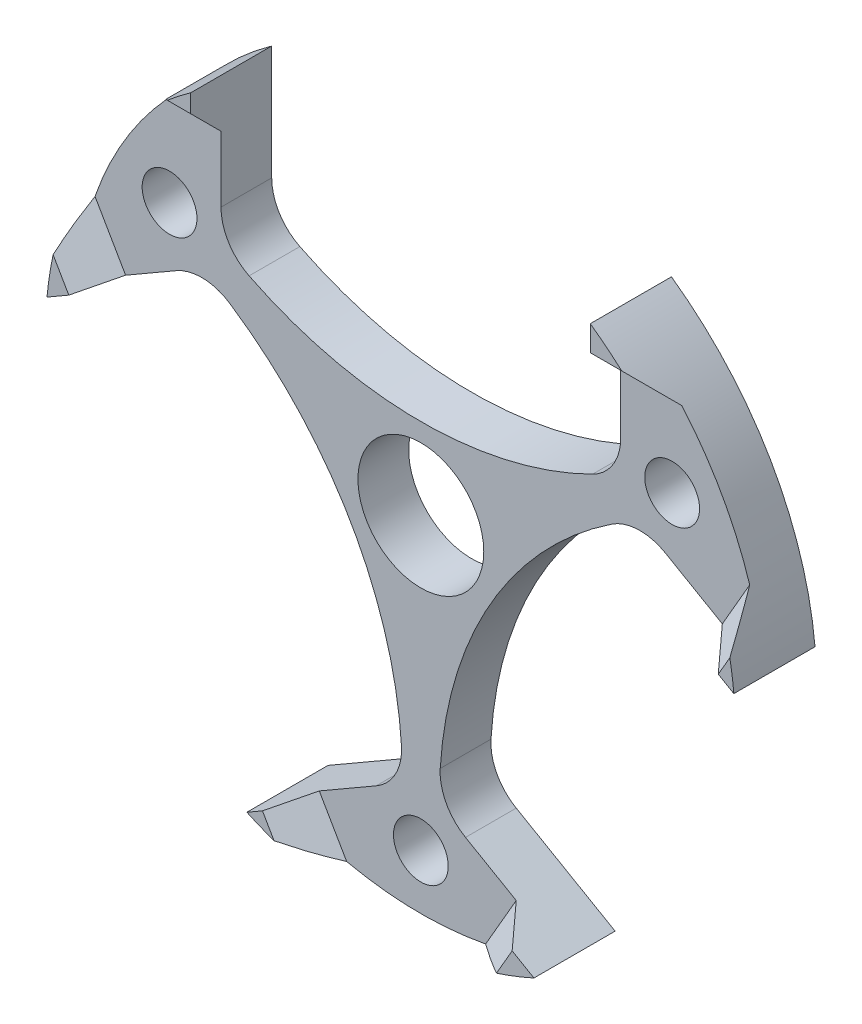
from build123d import *

# Parameters (mm, degrees)
ESQUISSE1_R                     = 17
BOSS_EXTRU_1_DEPTH              = 1.25
ENL_V_MAT_EXTRU_1_DEPTH         = 25.171263931
D_GAGEMENT_M2_51_D              = 2.7
R_P_TITION_CIRCULAIRE1_COUNT    = 3
DIAM_TRE_DU_PER_AGE_6_2_6_2_1_D = 6.2
BOSS_EXTRU_2_REACH              = 33.74
BOSS_EXTRU_2_END_RADIUS         = 17
BOSS_EXTRU_3_REACH              = 33.834
BOSS_EXTRU_3_END_RADIUS         = 17
R_P_TITION_CIRCULAIRE2_COUNT    = 3


with BuildPart() as part:
    # Esquisse1 → Boss.-Extru.1 (new, symmetric)
    with BuildSketch(Plane.XY):
        Circle(ESQUISSE1_R)
    extrude(amount=BOSS_EXTRU_1_DEPTH, both=True)

    # Esquisse2 → Enlèv. mat.-Extru.1 (cut, through all)
    with BuildSketch(Plane.XY.offset(1.25)):
        with BuildLine():
            Line((-9.85, 13.855594538), (-9.85, 8.227474827))
            ThreePointArc((-9.85, 8.227474827), (-9.475334198, 6.911057512), (-8.463636364, 5.989213437))
            ThreePointArc((-8.463636364, 5.989213437), (0, 4), (8.463636364, 5.989213437))
            ThreePointArc((8.463636364, 5.989213437), (9.475334198, 6.911057512), (9.85, 8.227474827))
            Line((9.85, 8.227474827), (9.85, 13.855594538))
            ThreePointArc((9.85, 13.855594538), (0, 17), (-9.85, 13.855594538))
        make_face()
    enl_v_mat_extru_1 = extrude(amount=-ENL_V_MAT_EXTRU_1_DEPTH, mode=Mode.SUBTRACT)

    # Dégagement M2.51 (through all)
    with Locations(Plane.XY.offset(1.25)):
        with Locations((12.384163274, 7.15)):
            d_gagement_m2_51 = Hole(D_GAGEMENT_M2_51_D / 2)

    # Répétition circulaire1: Enlèv. mat.-Extru.1, Dégagement M2.51 ×3 about axis
    r_p_tition_circulaire1_axis = Axis((0, 0, 0), (0, 0, 1))
    add([enl_v_mat_extru_1.rotate(r_p_tition_circulaire1_axis, i * 360 / R_P_TITION_CIRCULAIRE1_COUNT) for i in range(1, R_P_TITION_CIRCULAIRE1_COUNT)], mode=Mode.SUBTRACT)
    add([d_gagement_m2_51.rotate(r_p_tition_circulaire1_axis, i * 360 / R_P_TITION_CIRCULAIRE1_COUNT) for i in range(1, R_P_TITION_CIRCULAIRE1_COUNT)], mode=Mode.SUBTRACT)

    # Diamètre du perçage Ø6.2 (6.2)1 (through all)
    with Locations(Plane.XY.offset(1.25)):
        with Locations((0, 0)):
            Hole(DIAM_TRE_DU_PER_AGE_6_2_6_2_1_D / 2)

    # Boss.-Extru.2: up to this cylinder (the profile starts inside it)
    boss_extru_2_end = Plane(origin=(0, 0, 1.885519), z_dir=(0, 0, -1)) * Cylinder(BOSS_EXTRU_2_END_RADIUS, 102.48, mode=Mode.PRIVATE)
    # Esquisse8 → Boss.-Extru.2 (add, up to the surface)
    with BuildSketch(Plane(origin=(-9.85, 0, 0), x_dir=(0, 0, -1), z_dir=(1, 0, 0)), mode=Mode.PRIVATE) as boss_extru_2_sk1:
        Polygon((-1.25, 11.467766953), (-2.75, 12.967766953), (-2.75, 13.855594538), (-1.25, 13.855594538), align=None)
    boss_extru_2_tool1 = extrude(boss_extru_2_sk1.sketch, amount=-BOSS_EXTRU_2_REACH, mode=Mode.PRIVATE) & boss_extru_2_end
    boss_extru_2 = boss_extru_2_tool1.solids().sort_by_distance((-9.85, 12.97944, 1.885519))[0]
    add(boss_extru_2)

    # Boss.-Extru.3: up to this cylinder (the profile starts inside it)
    boss_extru_3_end = Plane(origin=(0, 0, 1.905844), z_dir=(0, 0, -1)) * Cylinder(BOSS_EXTRU_3_END_RADIUS, 102.668, mode=Mode.PRIVATE)
    # Esquisse9 → Boss.-Extru.3 (add, up to the surface)
    with BuildSketch(Plane.ZY.offset(-9.85), mode=Mode.PRIVATE) as boss_extru_3_sk1:
        Polygon((1.25, 13.855594538), (2.75, 13.855594538), (2.75, 12.614213562), (1.25, 11.114213562), align=None)
    boss_extru_3_tool1 = extrude(boss_extru_3_sk1.sketch, amount=-BOSS_EXTRU_3_REACH, mode=Mode.PRIVATE) & boss_extru_3_end
    boss_extru_3 = boss_extru_3_tool1.solids().sort_by_distance((9.85, 12.812826, 1.905844))[0]
    add(boss_extru_3)

    # Répétition circulaire2: Boss.-Extru.2, Boss.-Extru.3 ×3 about axis
    r_p_tition_circulaire2_axis = Axis((0, 0, 0), (0, 0, 1))
    add([boss_extru_2.rotate(r_p_tition_circulaire2_axis, i * 360 / R_P_TITION_CIRCULAIRE2_COUNT) for i in range(1, R_P_TITION_CIRCULAIRE2_COUNT)])
    add([boss_extru_3.rotate(r_p_tition_circulaire2_axis, i * 360 / R_P_TITION_CIRCULAIRE2_COUNT) for i in range(1, R_P_TITION_CIRCULAIRE2_COUNT)])


solid = part.part
